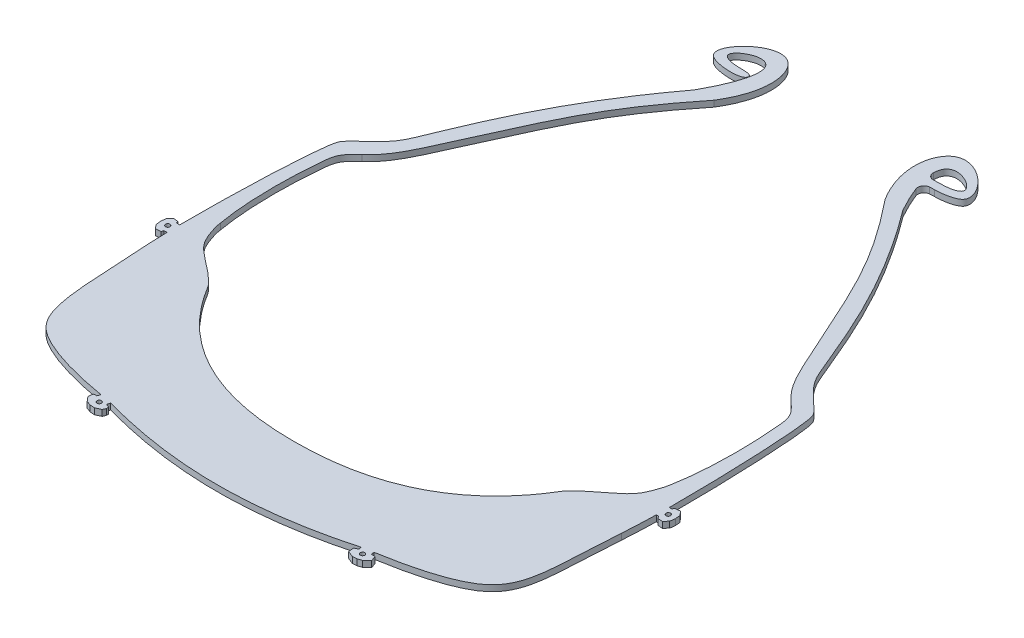
from build123d import *

# Parameters (mm, degrees)
SKETCH2_R           = 0.75
BOSS_EXTRUDE2_DEPTH = 2


with BuildPart() as part:
    # Sketch2 → Boss-Extrude2 (new body)
    with BuildSketch(Plane(origin=(0, 0, 0), x_dir=(1, 0, 0), z_dir=(0, 1, 0))):
        with BuildLine():
            Line((-16.94232243, 4635.297018365), (-18.534662591, 4633.795971308))
            Line((-18.534662591, 4633.795971308), (-19.887255597, 4633.340434244))
            Line((-19.887255597, 4633.340434244), (-21.312460887, 4633.264199495))
            Line((-21.312460887, 4633.264199495), (-23.346608072, 4634.07100473))
            Line((-23.346608072, 4634.07100473), (-23.480509856, 4635.86569876))
            Line((-23.480509856, 4635.86569876), (-22.26922003, 4636.472511323))
            Line((-22.26922003, 4636.472511323), (-22.498511996, 4637.355076027))
            add(Edge.make_bspline(
                [(-105.348248264, 4637.239361207), (-91.773973611, 4633.449581192), (-63.91646452, 4629.348089946), (-36.074978393, 4633.559092847), (-22.498511996, 4637.355076027)],
                knots=[0.018742307, 0.018742307, 0.018742307, 0.018742307, 0.500293183, 0.981944699, 0.981944699, 0.981944699, 0.981944699], degree=3))
            Line((-105.348248264, 4637.239361207), (-105.629701484, 4636.159523134))
            Line((-105.629701484, 4636.159523134), (-104.473549573, 4635.740406818))
            Line((-104.473549573, 4635.740406818), (-104.473549573, 4634.956711321))
            Line((-104.473549573, 4634.956711321), (-104.880493791, 4633.998010823))
            Line((-104.880493791, 4633.998010823), (-106.620311483, 4633.174408169))
            Line((-106.620311483, 4633.174408169), (-108.20431104, 4633.292684057))
            Line((-108.20431104, 4633.292684057), (-109.697513062, 4633.834340317))
            Line((-109.697513062, 4633.834340317), (-110.946606143, 4635.298940402))
            Line((-110.946606143, 4635.298940402), (-110.924641203, 4636.340202994))
            Line((-110.924641203, 4636.340202994), (-110.673720292, 4637.019084317))
            Line((-110.673720292, 4637.019084317), (-109.700510236, 4637.019084317))
            Line((-109.700510236, 4637.019084317), (-109.337236897, 4638.021190769))
            add(Edge.make_bspline(
                [(-109.337236897, 4638.021190769), (-119.14352525, 4639.685319313), (-132.602811475, 4643.251798031), (-144.259959312, 4654.289514228), (-143.359552227, 4671.437825607), (-144.749408582, 4689.48069966)],
                knots=[0.024855616, 0.024855616, 0.024855616, 0.024855616, 0.394717233, 0.49149328, 0.992616091, 0.992616091, 0.992616091, 0.992616091], degree=3))
            add(Edge.make_bspline(
                [(-144.749408582, 4689.48069966), (-144.833889745, 4691.307900212), (-144.896771823, 4693.342403801), (-144.93974364, 4695.519138342)],
                knots=[0.004734856, 0.004734856, 0.004734856, 0.004734856, 0.022822175, 0.022822175, 0.022822175, 0.022822175], degree=3))
            Line((-144.93974364, 4695.519138342), (-145.939352996, 4695.519138342))
            Line((-145.939352996, 4695.519138342), (-146.197672667, 4694.80522007))
            Line((-146.197672667, 4694.80522007), (-147.918372484, 4694.624725063))
            Line((-147.918372484, 4694.624725063), (-148.98298998, 4695.944509376))
            Line((-148.98298998, 4695.944509376), (-149.222790895, 4697.597182293))
            Line((-149.222790895, 4697.597182293), (-149.027988208, 4699.255761252))
            Line((-149.027988208, 4699.255761252), (-147.918372484, 4700.606196913))
            Line((-147.918372484, 4700.606196913), (-146.274658466, 4700.470317954))
            Line((-146.274658466, 4700.470317954), (-146.077436972, 4699.790846236))
            Line((-146.077436972, 4699.790846236), (-144.997793977, 4699.790846236))
            add(Edge.make_bspline(
                [(-144.997793977, 4699.790846236), (-145.140739705, 4717.900779), (-143.980500661, 4747.781377705), (-140.945923977, 4752.343565924), (-133.518576886, 4758.089574725), (-125.834261615, 4776.287708079), (-117.105500852, 4798.926600097), (-98.491339322, 4823.690578863)],
                knots=[0.034255764, 0.034255764, 0.034255764, 0.034255764, 0.174203465, 0.204984692, 0.326836548, 0.407861227, 1, 1, 1, 1], degree=3))
            add(Edge.make_bspline(
                [(-98.491339322, 4823.690578863), (-93.366839688, 4832.95705297), (-89.941800493, 4849.378885104), (-105.785500967, 4840.51815915), (-99.876937155, 4837.046976634), (-93.638768067, 4838.042303186), (-92.634176249, 4834.170539469), (-104.644385531, 4834.751057475), (-107.756168887, 4841.844497822), (-89.719573279, 4857.079771819), (-85.226019927, 4835.342195387), (-92.265822948, 4824.036656848)],
                knots=[0, 0, 0, 0, 0.048334816, 0.142928243, 0.162159562, 0.231927069, 0.259382175, 0.409255519, 0.461523944, 0.763332252, 1, 1, 1, 1], degree=3))
            add(Edge.make_bspline(
                [(-135.032740768, 4750.111001922), (-130.492715197, 4753.903311112), (-113.370176945, 4791.307654005), (-108.954027961, 4803.20893759), (-92.265822948, 4824.036656848)],
                knots=[0, 0, 0, 0, 0.147117654, 0.925748444, 0.925748444, 0.925748444, 0.925748444], degree=3))
            add(Edge.make_bspline(
                [(-138.776603849, 4707.061813065), (-140.372417965, 4715.665959829), (-140.797792532, 4730.905308146), (-139.055824108, 4746.24867545), (-136.530200286, 4748.70910668), (-135.032740768, 4750.111001922)],
                knots=[0, 0, 0, 0, 0.797699661, 0.897699661, 1, 1, 1, 1], degree=3))
            add(Edge.make_bspline(
                [(-122.553716851, 4686.669702846), (-124.458572981, 4689.514746254), (-133.378914312, 4695.631638467), (-134.862520268, 4697.627016687), (-136.765281392, 4699.957235784), (-138.495666225, 4704.644766972), (-138.776603849, 4707.061813065)],
                knots=[0, 0, 0, 0, 0.517384858, 0.711983816, 0.762677817, 1, 1, 1, 1], degree=3))
            add(Edge.make_bspline(
                [(-63.92338013, 4656.572608608), (-104.524638736, 4656.452117341), (-122.553716851, 4686.669702846)],
                knots=[0, 0, 0, 1, 1, 1], degree=2))
            add(Edge.make_bspline(
                [(-63.92338013, 4656.572608608), (-23.322121525, 4656.452117341), (-5.29304341, 4686.669702846)],
                knots=[0, 0, 0, 1, 1, 1], degree=2))
            add(Edge.make_bspline(
                [(-5.29304341, 4686.669702846), (-3.38818728, 4689.514746254), (5.532154051, 4695.631638467), (7.015760007, 4697.627016687), (8.918521131, 4699.957235784), (10.648905964, 4704.644766972), (10.929843589, 4707.061813065)],
                knots=[0, 0, 0, 0, 0.517384858, 0.711983816, 0.762677817, 1, 1, 1, 1], degree=3))
            add(Edge.make_bspline(
                [(10.929843589, 4707.061813065), (12.525657705, 4715.665959829), (12.951032272, 4730.905308146), (11.209063847, 4746.24867545), (8.683440025, 4748.70910668), (7.185980508, 4750.111001922)],
                knots=[0, 0, 0, 0, 0.797699661, 0.897699661, 1, 1, 1, 1], degree=3))
            add(Edge.make_bspline(
                [(7.185980508, 4750.111001922), (2.645954936, 4753.903311112), (-14.476583316, 4791.307654005), (-18.8927323, 4803.20893759), (-35.580937313, 4824.036656848)],
                knots=[0, 0, 0, 0, 0.147117654, 0.925748444, 0.925748444, 0.925748444, 0.925748444], degree=3))
            add(Edge.make_bspline(
                [(-30.16155738, 4834.871628771), (-27.376780391, 4834.869219449), (-22.614912719, 4835.830338941), (-20.677963293, 4842.07922902), (-38.128247821, 4857.07739084), (-42.620740333, 4835.342195387), (-35.580937313, 4824.036656848)],
                knots=[0.329045507, 0.329045507, 0.329045507, 0.329045507, 0.418095269, 0.461523944, 0.763332252, 1, 1, 1, 1], degree=3))
            Line((-30.16155738, 4834.871628771), (-31.646107508, 4834.799675676))
            ThreePointArc((-31.646107508, 4834.799675676), (-33.223661528, 4833.895850729), (-33.417520966, 4832.088091138))
            add(Edge.make_bspline(
                [(-29.412709692, 4823.690578863), (-30.308473234, 4825.310360357), (-31.857622797, 4828.323020224), (-32.964264892, 4830.901994868), (-33.417520966, 4832.088091138)],
                knots=[0, 0, 0, 0, 0.008448935, 0.016897871, 0.016897871, 0.016897871, 0.016897871], degree=3))
            add(Edge.make_bspline(
                [(17.151033717, 4699.790846236), (17.186998591, 4718.753185432), (15.946347275, 4748.148669169), (12.996152442, 4752.2097804), (5.590214635, 4758.138556503), (-2.080663876, 4776.079890469), (-10.798548161, 4798.926600097), (-29.412709692, 4823.690578863)],
                knots=[0.044450265, 0.044450265, 0.044450265, 0.044450265, 0.175222915, 0.204984692, 0.326836548, 0.407861227, 1, 1, 1, 1], degree=3))
            Line((17.151033717, 4699.790846236), (17.927254585, 4699.790846236))
            Line((17.927254585, 4699.790846236), (18.427898205, 4700.470317954))
            Line((18.427898205, 4700.470317954), (20.071612224, 4700.606196913))
            Line((20.071612224, 4700.606196913), (21.181227948, 4699.255761252))
            Line((21.181227948, 4699.255761252), (21.376030634, 4697.597182293))
            Line((21.376030634, 4697.597182293), (21.136229719, 4695.944509376))
            Line((21.136229719, 4695.944509376), (19.990327064, 4694.624725063))
            Line((19.990327064, 4694.624725063), (18.350912407, 4694.80522007))
            Line((18.350912407, 4694.80522007), (17.926998071, 4695.519138342))
            Line((17.926998071, 4695.519138342), (17.092983379, 4695.519138342))
            add(Edge.make_bspline(
                [(16.61721801, 4684.514714632), (16.759333405, 4687.588466409), (17.055168032, 4691.324791696), (17.092983379, 4695.519138342)],
                knots=[0.004734857, 0.004734857, 0.004734857, 0.004734857, 0.035161677, 0.035161677, 0.035161677, 0.035161677], degree=3))
            add(Edge.make_bspline(
                [(-18.943384636, 4638.035656948), (-9.024791136, 4639.685871765), (4.646728482, 4643.060373116), (16.372015333, 4654.394416396), (15.252352932, 4666.334603474), (16.61721801, 4684.514714632)],
                knots=[0.018902136, 0.018902136, 0.018902136, 0.018902136, 0.394121885, 0.490994555, 0.987628845, 0.987628845, 0.987628845, 0.987628845], degree=3))
            Line((-18.943384636, 4638.035656948), (-18.723139757, 4637.014274136))
            Line((-18.723139757, 4637.014274136), (-17.480735808, 4637.014274136))
            Line((-17.480735808, 4637.014274136), (-16.94232243, 4635.297018365))
        make_face()
        with Locations((-20.331640643, 4635.661753265)):
            Circle(SKETCH2_R, mode=Mode.SUBTRACT)
        with Locations((-107.515119617, 4635.661753265)):
            Circle(SKETCH2_R, mode=Mode.SUBTRACT)
        with Locations((18.97346222, 4697.629831976)):
            Circle(SKETCH2_R, mode=Mode.SUBTRACT)
        with Locations((-146.82022248, 4697.629831976)):
            Circle(SKETCH2_R, mode=Mode.SUBTRACT)
        with BuildLine():
            Line((-32.326997859, 4837.493206847), (-33.002005847, 4837.456919553))
            ThreePointArc((-33.002005847, 4837.456919553), (-34.491071441, 4838.008043416), (-35.109299497, 4839.470523475))
            add(Edge.make_bspline(
                [(-35.109299497, 4839.470523475), (-35.103487171, 4840.17555248), (-34.108770825, 4847.223419654), (-22.361772328, 4840.691756076), (-27.115040709, 4837.451233562), (-30.532335901, 4837.589684854), (-32.326997859, 4837.493206847)],
                knots=[0.039445136, 0.039445136, 0.039445136, 0.039445136, 0.048334816, 0.142928243, 0.159172541, 0.210777803, 0.210777803, 0.210777803, 0.210777803], degree=3))
        make_face(mode=Mode.SUBTRACT)
    extrude(amount=BOSS_EXTRUDE2_DEPTH)


solid = part.part
